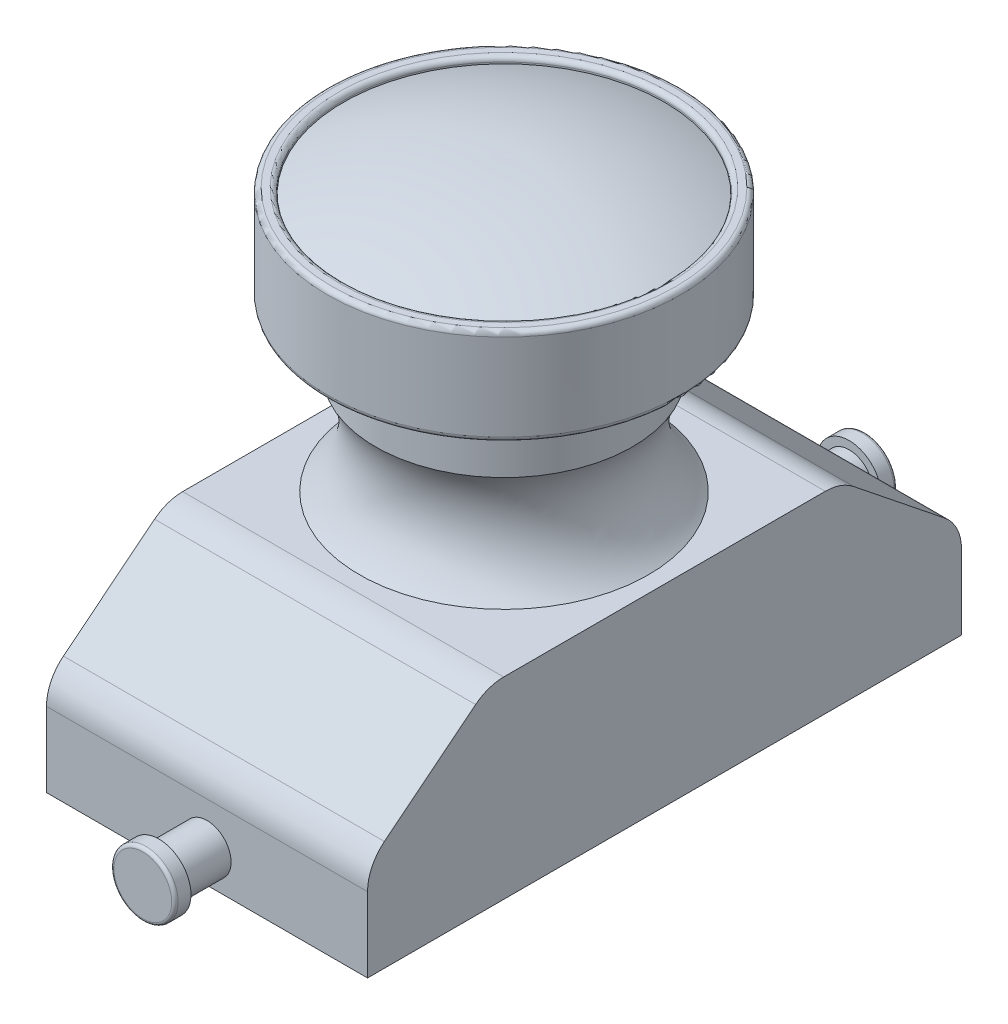
from build123d import *

# Parameters (mm, degrees)
BOSS_EXTRUDE1_DEPTH  = 5
FILLET1_R            = 0.15
FILLET2_R            = 1.4
SKETCH4_R            = 0.75
BOSS_EXTRUDE2_DEPTH  = 2
SKETCH5_R            = 1
BOSS_EXTRUDE3_DEPTH  = 0.5
FILLET3_R            = 0.1
FILLET3_OF_MIRROR2_R = 0.1


with BuildPart() as part:
    # Sketch1 → Boss-Extrude1 (new body, symmetric)
    with BuildSketch(Plane(origin=(0, 0, 0), x_dir=(0, 0, -1), z_dir=(1, 0, 0))):
        Polygon((9.25, 3), (5.5, 6), (-5.5, 6), (-9.25, 3), (-9.25, 0), (9.25, 0), align=None)
    extrude(amount=BOSS_EXTRUDE1_DEPTH, both=True)

    # Sketch2 → Revolve1 (revolve)
    with BuildSketch(Plane(origin=(0, 0, 0), x_dir=(0, 0, -1), z_dir=(1, 0, 0))):
        with BuildLine():
            Line((0, 6), (0, 14))
            Line((0, 14), (5, 14))
            Line((5, 14), (5, 14.2))
            Line((5, 14.2), (5.5, 14.2))
            Line((5.5, 14.2), (5.5, 11.2))
            Line((5.5, 11.2), (4, 11.2))
            Line((4, 11.2), (4, 9.2))
            ThreePointArc((4, 9.2), (3.661737334, 7.508083958), (4.5, 6))
            Line((4.5, 6), (0, 6))
        make_face()
    revolve(axis=Axis((0, 0, 0), (0, 1, 0)))

    # Sketch3 → Revolve2 (revolve)
    with BuildSketch(Plane(origin=(0, 0, 0), x_dir=(0, 0, -1), z_dir=(1, 0, 0))):
        with BuildLine():
            Line((0, 14.2), (0, 15))
            ThreePointArc((0, 15), (-2.553728094, 14.768640471), (-5, 14))
            Line((-5, 14), (0, 14))
            Line((0, 14), (0, 14.2))
        make_face()
    revolve(axis=Axis((0, 14.2, 0), (0, -1, 0)))

    # Fillet1
    fillet1_edges = [part.edges().sort_by_distance(p)[0] for p in [
        (0, 11.2, 5.5),
        (0, 14.2, 5.5),
        (0, 14.2, 5),
    ]]
    fillet(fillet1_edges, radius=FILLET1_R)

    # Fillet2
    fillet2_edges = [part.edges().sort_by_distance(p)[0] for p in [
        (0, 3, 9.25),
        (0, 6, 5.5),
        (0, 6, -5.5),
        (0, 3, -9.25),
    ]]
    fillet(fillet2_edges, radius=FILLET2_R)

    # Sketch4 → Boss-Extrude2 (add)
    with BuildSketch(Plane(origin=(0, 0, -9.25), x_dir=(-1, 0, 0), z_dir=(0, 0, -1))):
        with Locations((0, 1)):
            Circle(SKETCH4_R)
    boss_extrude2 = extrude(amount=BOSS_EXTRUDE2_DEPTH)

    # Mirror1: Boss-Extrude2 across plane
    add(boss_extrude2.mirror(Plane.XY))

    # Sketch5 → Boss-Extrude3 (add)
    with BuildSketch(Plane.XY.offset(11.25)):
        with Locations((0, 1)):
            Circle(SKETCH5_R)
    boss_extrude3 = extrude(amount=-BOSS_EXTRUDE3_DEPTH)

    # Fillet3
    fillet3_edges = [part.edges().sort_by_distance(p)[0] for p in [
        (-1, 1, 11.25),
    ]]
    fillet(fillet3_edges, radius=FILLET3_R)

    # Mirror2: Boss-Extrude3 across plane
    add(boss_extrude3.mirror(Plane.XY))

    # Fillet3 of Mirror2
    fillet3_of_mirror2_edges = [part.edges().sort_by_distance(p)[0] for p in [
        (-1, 1, -11.25),
    ]]
    fillet(fillet3_of_mirror2_edges, radius=FILLET3_OF_MIRROR2_R)


solid = part.part
